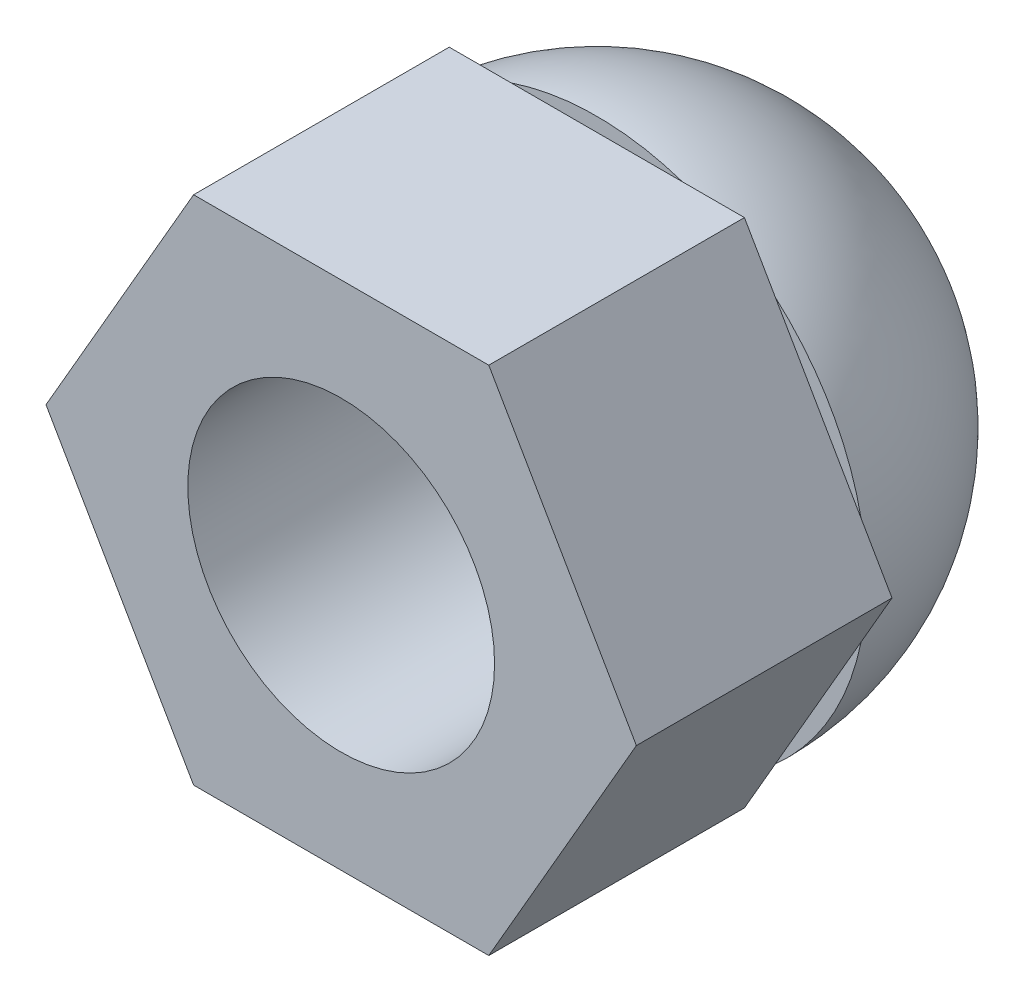
from build123d import *

# Parameters (mm, degrees)
ESBO_O1_R                = 3
RESSALTO_EXTRUS_O1_DEPTH = 5


with BuildPart() as part:
    # Esboço1 → Ressalto-extrusão1 (new body)
    with BuildSketch(Plane.XY):
        Polygon((2.886751346, 5), (-2.886751346, 5), (-5.773502692, 0), (-2.886751346, -5), (2.886751346, -5), (5.773502692, 0), align=None)
        Circle(ESBO_O1_R, mode=Mode.SUBTRACT)
    extrude(amount=RESSALTO_EXTRUS_O1_DEPTH)

    # Esboço2 → Revolução1 (revolve)
    with BuildSketch(Plane(origin=(0, 0, 0), x_dir=(1, 0, 0), z_dir=(0, 1, 0))):
        with BuildLine():
            Line((0, 0), (5.273502692, 0))
            ThreePointArc((5.273502692, 0), (3.728929514, 3.728929514), (0, 5.273502692))
            Line((0, 5.273502692), (0, 0))
        make_face()
    revolve(axis=Axis((0, 0, -5.273502692), (0, 0, 1)))


solid = part.part
